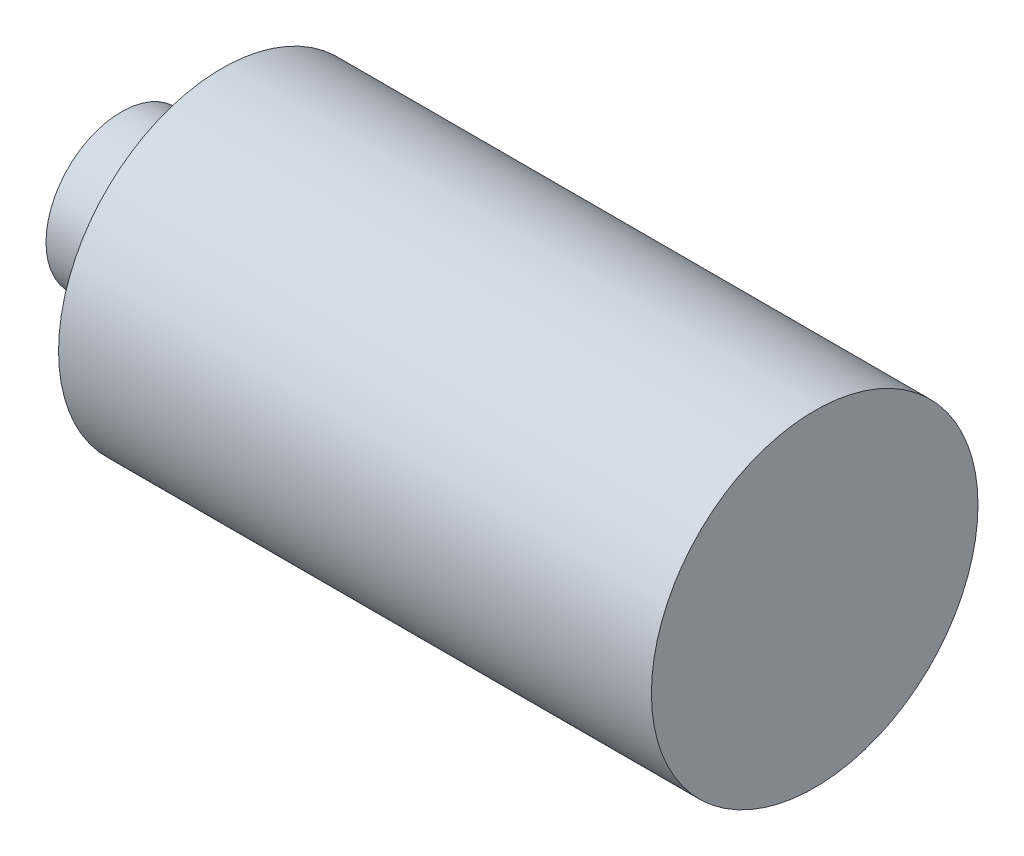
from build123d import *


with BuildPart() as part:
    # Sketch1 → Revolve1 (revolve)
    with BuildSketch(Plane.XY):
        Polygon((11.8, 0), (11.8, 3.25), (0, 3.25), (0, 1.5), (-2, 1.5), (-2, 0), align=None)
    revolve(axis=Axis((-14.130434783, 0, 0), (1, 0, 0)))


solid = part.part
